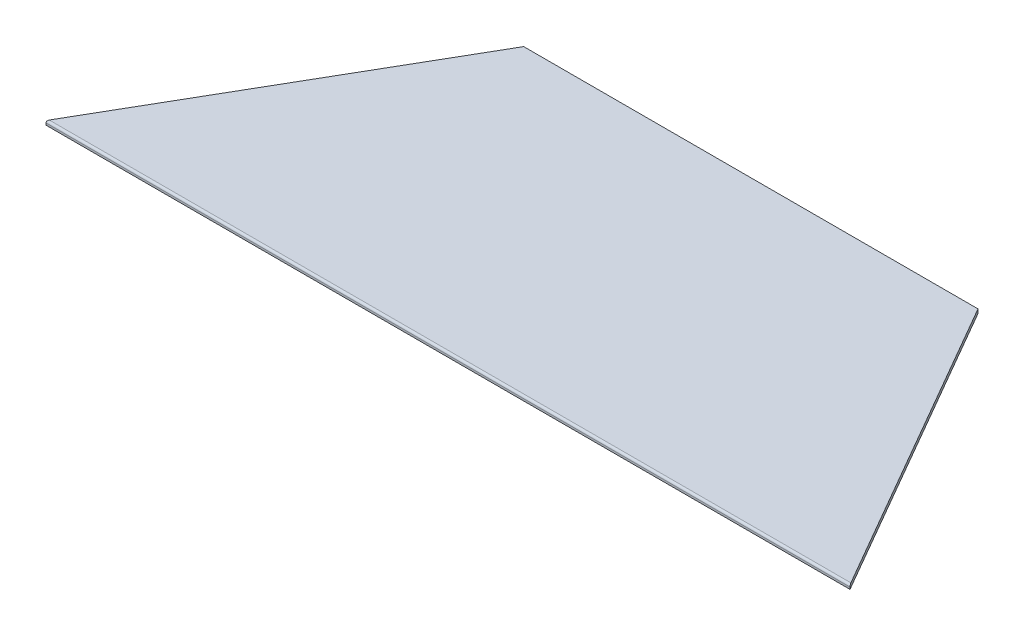
from build123d import *

# Parameters (mm, degrees)
BOSS_EXTRUDE1_DEPTH = 2.0574
FILLET1_R           = 1.0287


with BuildPart() as part:
    # Sketch1 → Boss-Extrude1 (new body)
    with BuildSketch(Plane(origin=(0, 0, 0), x_dir=(1, 0, 0), z_dir=(0, 1, 0))):
        Polygon((0, 0), (404.576362049, 0), (316.588181024, 152.4), (87.988181024, 152.4), align=None)
    extrude(amount=BOSS_EXTRUDE1_DEPTH)

    # Fillet1
    fillet1_edges = [part.edges().sort_by_distance(p)[0] for p in [
        (202.288181024, 2.0574, 0),
    ]]
    fillet(fillet1_edges, radius=FILLET1_R)


solid = part.part
